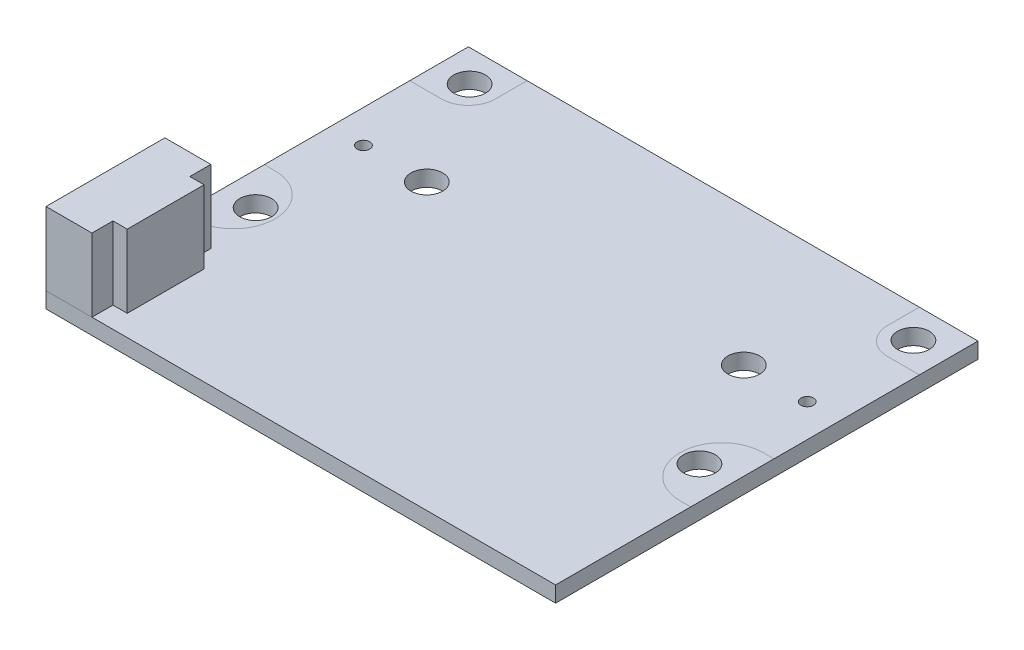
from build123d import *

# Parameters (mm, degrees)
SKETCH1_W           = 32.15
SKETCH1_H           = 26.65
SKETCH1_R           = 1
SKETCH1_R_2         = 0.4
BOSS_EXTRUDE1_DEPTH = 1
BOSS_EXTRUDE3_DEPTH = 4.6


with BuildPart() as part:
    # Sketch1 → Boss-Extrude1 (new body)
    with BuildSketch(Plane(origin=(0, 0, 0), x_dir=(1, 0, 0), z_dir=(0, 1, 0))):
        with Locations((0, -4.625)):
            Rectangle(SKETCH1_W, SKETCH1_H)
        with Locations((14, 6.7)):
            Circle(SKETCH1_R, mode=Mode.SUBTRACT)
        with Locations((14, -6.8)):
            Circle(SKETCH1_R, mode=Mode.SUBTRACT)
        with Locations((14, 0)):
            Circle(SKETCH1_R_2, mode=Mode.SUBTRACT)
        with Locations((10, 0)):
            Circle(SKETCH1_R, mode=Mode.SUBTRACT)
        with Locations((-14, 0)):
            Circle(SKETCH1_R_2, mode=Mode.SUBTRACT)
        with Locations((-14, -6.8)):
            Circle(SKETCH1_R, mode=Mode.SUBTRACT)
        with Locations((-14, 6.7)):
            Circle(SKETCH1_R, mode=Mode.SUBTRACT)
        with Locations((-10, 0)):
            Circle(SKETCH1_R, mode=Mode.SUBTRACT)
    extrude(amount=BOSS_EXTRUDE1_DEPTH)


with BuildPart() as body_2:
    # Sketch5 → Boss-Extrude3 (new body)
    with BuildSketch(Plane(origin=(0, 1, 0), x_dir=(1, 0, 0), z_dir=(0, 1, 0))):
        Polygon((-16.075, -17.95), (-13.175, -17.95), (-13.175, -16.625), (-12.275, -16.625), (-12.275, -11.775), (-13.175, -11.775), (-13.175, -10.45), (-16.075, -10.45), align=None)
    extrude(amount=BOSS_EXTRUDE3_DEPTH)


solid = Compound([part.part, body_2.part])
